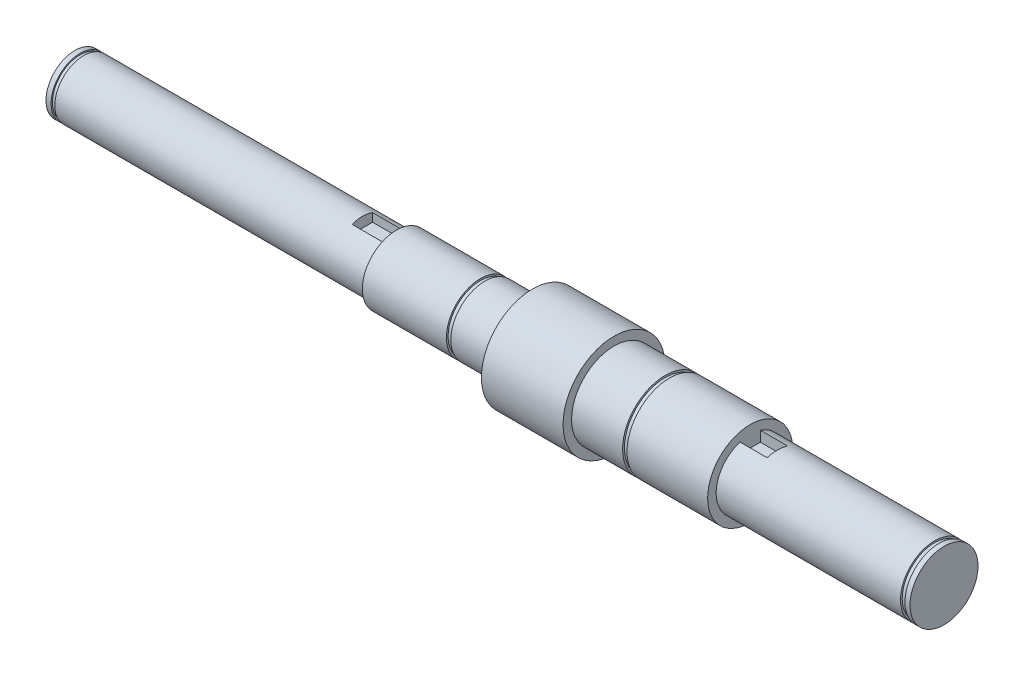
from build123d import *

# Parameters (mm, degrees)
SKETCH2_W          = 6
SKETCH2_H          = 5.3
CUT_EXTRUDE1_DEPTH = 10
SKETCH3_W          = 6
SKETCH3_H          = 3.5
CUT_EXTRUDE2_DEPTH = 8


with BuildPart() as part:
    # Sketch1 → Revolve1 (revolve)
    with BuildSketch(Plane.XY):
        Polygon((-127.75, 0), (127.75, 0), (127.75, 10), (126.25, 10), (126.25, 9.5), (124.95, 9.5), (124.95, 10), (70.75, 10), (70.75, 12.5), (47.05, 12.5), (47.05, 11.95), (45.75, 11.95), (45.75, 12.5), (30.75, 12.5), (30.75, 15), (6.75, 15), (6.75, 10), (-7.25, 10), (-7.25, 9.5), (-8.55, 9.5), (-8.55, 10), (-33.25, 10), (-33.25, 8.5), (-125.15, 8.5), (-125.15, 8.1), (-126.25, 8.1), (-126.25, 8.5), (-127.75, 8.5), align=None)
    revolve(axis=Axis((-127.75, 0, 0), (1, 0, 0)))

    # Sketch2 → Cut-Extrude1 (cut)
    with BuildSketch(Plane.ZY.offset(33.25)):
        with Locations((0, 8.15)):
            Rectangle(SKETCH2_W, SKETCH2_H)
    extrude(amount=CUT_EXTRUDE1_DEPTH, mode=Mode.SUBTRACT)

    # Sketch3 → Cut-Extrude2 (cut)
    with BuildSketch(Plane(origin=(70.75, 0, 0), x_dir=(0, 0, -1), z_dir=(1, 0, 0))):
        with Locations((0, 8.25)):
            Rectangle(SKETCH3_W, SKETCH3_H)
    extrude(amount=CUT_EXTRUDE2_DEPTH, mode=Mode.SUBTRACT)


solid = part.part
